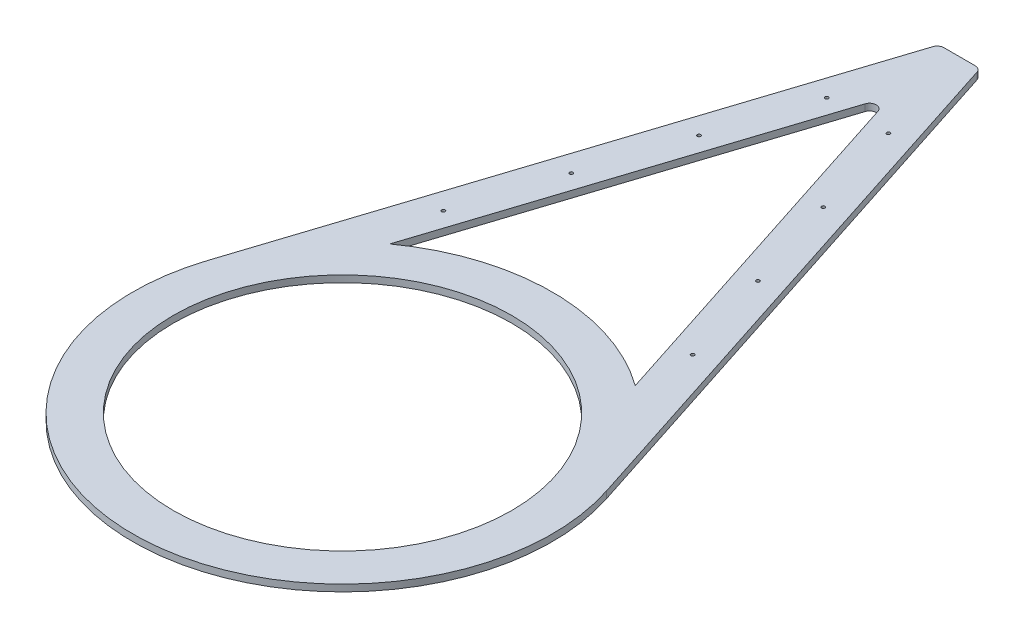
from build123d import *

# Parameters (mm, degrees)
SKETCH2_R           = 250
SKETCH2_R_2         = 2.5
BOSS_EXTRUDE1_DEPTH = 10


with BuildPart() as part:
    # Sketch2 → Boss-Extrude1 (new body)
    with BuildSketch(Plane(origin=(0, 0, 0), x_dir=(1, 0, 0), z_dir=(0, 1, 0))):
        with BuildLine():
            Line((-32.627158959, 905.183764104), (-294.863184644, 95.498530059))
            ThreePointArc((-294.863184644, 95.498530059), (0, -309.942360613), (294.863184644, 95.498530059))
            Line((294.863184644, 95.498530059), (32.627158959, 905.183764104))
            ThreePointArc((32.627158959, 905.183764104), (28.995353361, 910.189981994), (23.11367445, 912.102593467))
            Line((23.11367445, 912.102593467), (-23.11367445, 912.102593467))
            ThreePointArc((-23.11367445, 912.102593467), (-28.995353361, 910.189981994), (-32.627158959, 905.183764104))
        make_face()
        Circle(SKETCH2_R, mode=Mode.SUBTRACT)
        with Locations((-184.210314713, 333.331115971)):
            Circle(SKETCH2_R_2, mode=Mode.SUBTRACT)
        with Locations((-137.992755162, 476.03338361)):
            Circle(SKETCH2_R_2, mode=Mode.SUBTRACT)
        with Locations((-91.775195611, 618.735651249)):
            Circle(SKETCH2_R_2, mode=Mode.SUBTRACT)
        with Locations((-45.557636061, 761.437918887)):
            Circle(SKETCH2_R_2, mode=Mode.SUBTRACT)
        with BuildLine():
            ThreePointArc((181.388362207, 251.321564848), (0, 309.942360613), (-181.388362207, 251.321564848))
            Line((-181.388362207, 251.321564848), (-9.513484509, 782.005898596))
            ThreePointArc((-9.513484509, 782.005898596), (0, 788.92472796), (9.513484509, 782.005898596))
            Line((9.513484509, 782.005898596), (181.388362207, 251.321564848))
        make_face(mode=Mode.SUBTRACT)
        with Locations((137.992755162, 476.03338361)):
            Circle(SKETCH2_R_2, mode=Mode.SUBTRACT)
        with Locations((184.210314713, 333.331115971)):
            Circle(SKETCH2_R_2, mode=Mode.SUBTRACT)
        with Locations((91.775195611, 618.735651249)):
            Circle(SKETCH2_R_2, mode=Mode.SUBTRACT)
        with Locations((45.557636061, 761.437918887)):
            Circle(SKETCH2_R_2, mode=Mode.SUBTRACT)
    extrude(amount=BOSS_EXTRUDE1_DEPTH)


solid = part.part
